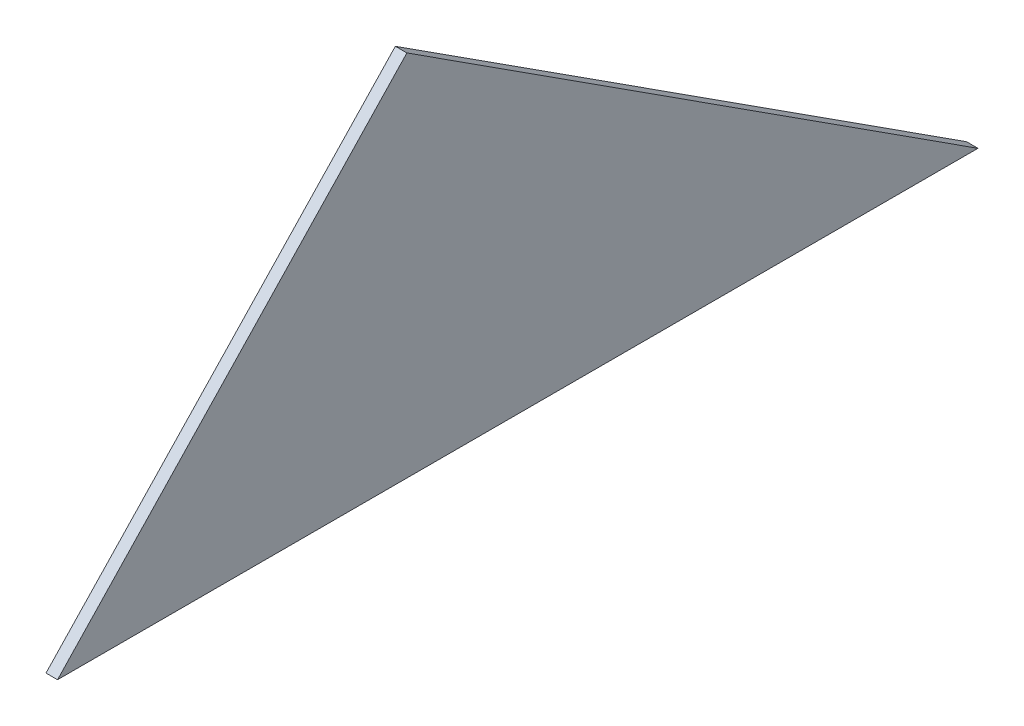
from build123d import *

# Parameters (mm, degrees)
BOSS_EXTRUDE1_DEPTH = 6.35


with BuildPart() as part:
    # Sketch1 → Boss-Extrude1 (new body)
    with BuildSketch(Plane(origin=(0, 0, 0), x_dir=(0, 0, -1), z_dir=(1, 0, 0))):
        Polygon((0, 0), (506.73, 0), (192.326268449, 202.669599261), align=None)
    extrude(amount=BOSS_EXTRUDE1_DEPTH)


solid = part.part
